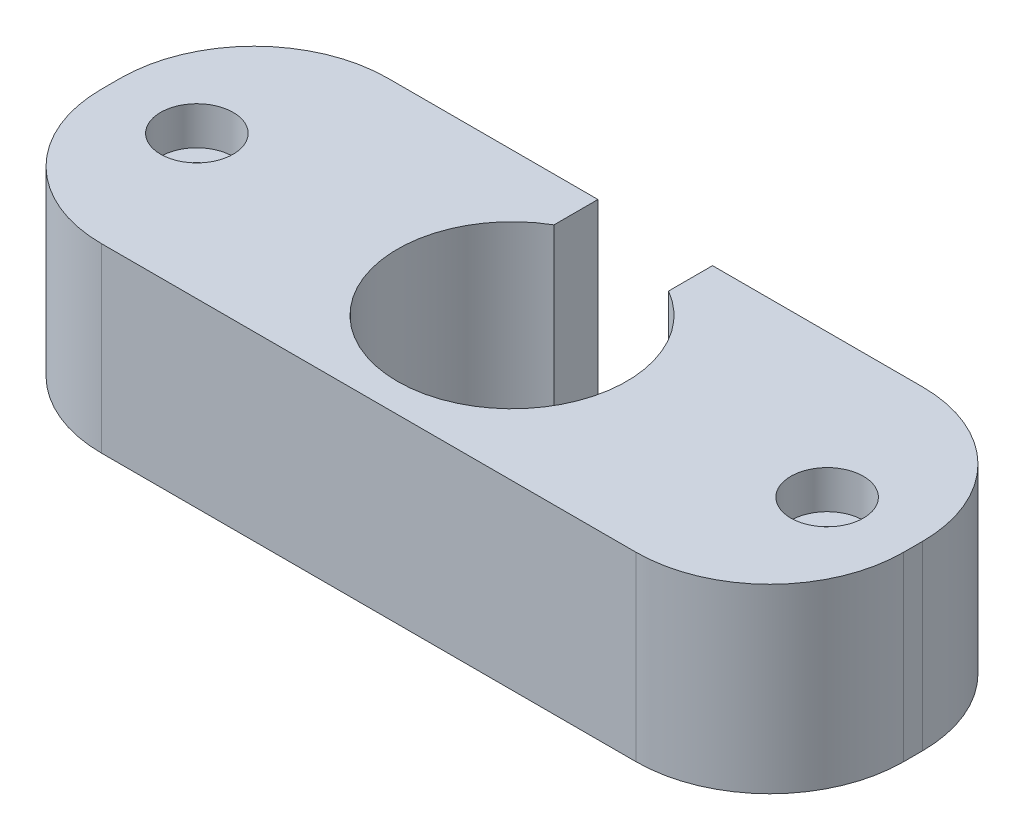
from build123d import *

# Parameters (mm, degrees)
SKETCH1_W           = 42
SKETCH1_H           = 15
BOSS_EXTRUDE1_DEPTH = 9.5
CUT_EXTRUDE1_REACH  = 11.5
SKETCH2_R           = 6
SKETCH4_R           = 1.9
CUT_EXTRUDE3_DEPTH  = 2
SKETCH5_R           = 2.05
CUT_EXTRUDE4_DEPTH  = 5
SKETCH6_R           = 0.95
CUT_EXTRUDE5_DEPTH  = 3
FILLET1_R           = 7
SKETCH7_W           = 6
SKETCH7_H           = 9.5
CUT_EXTRUDE6_DEPTH  = 3


with BuildPart() as part:
    # Sketch1 → Boss-Extrude1 (new body)
    with BuildSketch(Plane(origin=(0, 0, 0), x_dir=(1, 0, 0), z_dir=(0, 1, 0))):
        with Locations((21, 7.5)):
            Rectangle(SKETCH1_W, SKETCH1_H)
    extrude(amount=-BOSS_EXTRUDE1_DEPTH)

    # Sketch2 → Cut-Extrude1 (cut, up to next)
    with BuildSketch(Plane(origin=(0, 0, 0), x_dir=(1, 0, 0), z_dir=(0, 1, 0)), mode=Mode.PRIVATE) as cut_extrude1_sk1:
        with Locations((21, 7.5)):
            Circle(SKETCH2_R)
    cut_extrude1_tool1 = extrude(cut_extrude1_sk1.sketch, amount=-CUT_EXTRUDE1_REACH, mode=Mode.PRIVATE) & part.part
    add(cut_extrude1_tool1.solids().sort_by_distance((21, 0, -7.5))[0], mode=Mode.SUBTRACT)

    # Sketch4 → Cut-Extrude3 (cut)
    with BuildSketch(Plane(origin=(0, 0, 0), x_dir=(1, 0, 0), z_dir=(0, 1, 0))):
        with Locations((4.5, 7.5)):
            Circle(SKETCH4_R)
        with Locations((37.5, 7.5)):
            Circle(SKETCH4_R)
    extrude(amount=-CUT_EXTRUDE3_DEPTH, mode=Mode.SUBTRACT)

    # Sketch5 → Cut-Extrude4 (cut)
    with BuildSketch(Plane(origin=(0, -9.5, 0), x_dir=(-1, 0, 0), z_dir=(0, -1, 0))):
        with Locations((-37.5, 7.5)):
            Circle(SKETCH5_R)
        with Locations((-4.5, 7.5)):
            Circle(SKETCH5_R)
    extrude(amount=-CUT_EXTRUDE4_DEPTH, mode=Mode.SUBTRACT)

    # Sketch6 → Cut-Extrude5 (cut)
    with BuildSketch(Plane(origin=(0, -2, 0), x_dir=(1, 0, 0), z_dir=(0, 1, 0))):
        with Locations((4.5, 7.5)):
            Circle(SKETCH6_R)
        with Locations((37.5, 7.5)):
            Circle(SKETCH6_R)
    extrude(amount=-CUT_EXTRUDE5_DEPTH, mode=Mode.SUBTRACT)

    # Fillet1
    fillet1_edges = [part.edges().sort_by_distance(p)[0] for p in [
        (0, -4.75, -15),
        (42, -4.75, -15),
        (42, -4.75, 0),
        (0, -4.75, 0),
    ]]
    fillet(fillet1_edges, radius=FILLET1_R)

    # Sketch7 → Cut-Extrude6 (cut)
    with BuildSketch(Plane(origin=(0, 0, -15), x_dir=(-1, 0, 0), z_dir=(0, 0, -1))):
        with Locations((-21, -4.75)):
            Rectangle(SKETCH7_W, SKETCH7_H)
    extrude(amount=-CUT_EXTRUDE6_DEPTH, mode=Mode.SUBTRACT)


solid = part.part
